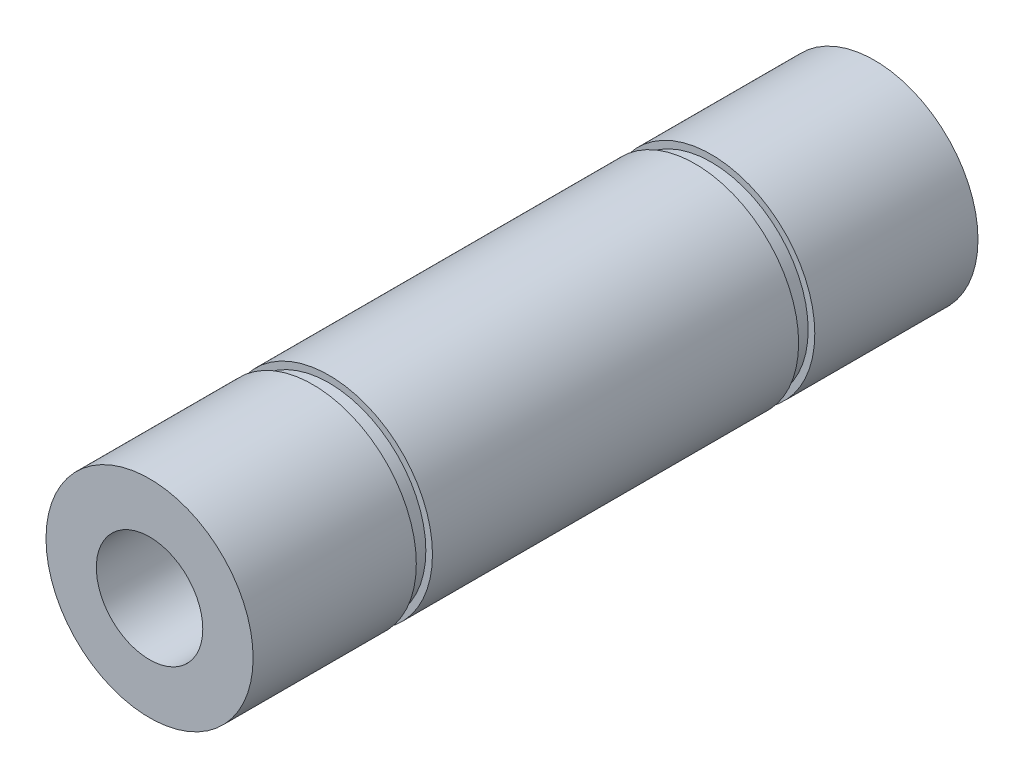
from build123d import *

# Parameters (mm, degrees)
SKETCH1_R                    = 6.35
EXTRUDE1_DEPTH               = 22.225
F_5_16_18_TAPPED_HOLE1_D     = 6.5278
F_5_16_18_TAPPED_HOLE1_DEPTH = 20.32
F_5_16_18_TAPPED_HOLE1_TIP   = 1.961148974
F_5_16_18_TAPPED_HOLE2_D     = 6.5278
F_5_16_18_TAPPED_HOLE2_DEPTH = 20.32
F_5_16_18_TAPPED_HOLE2_TIP   = 1.961148974
SKETCH6_W                    = 0.9906
SKETCH6_H                    = 0.4064


with BuildPart() as part:
    # Sketch1 → Extrude1 (new body, symmetric)
    with BuildSketch(Plane.XY):
        Circle(SKETCH1_R)
    extrude(amount=EXTRUDE1_DEPTH, both=True)

    # 5/16-18 Tapped Hole1
    with Locations(Plane.XY.offset(22.225)):
        with Locations((0, 0)):
            Hole(F_5_16_18_TAPPED_HOLE1_D / 2, depth=F_5_16_18_TAPPED_HOLE1_DEPTH)
            with Locations((0, 0, -(F_5_16_18_TAPPED_HOLE1_DEPTH + F_5_16_18_TAPPED_HOLE1_TIP / 2))):  # 118° drill point
                Cone(0, F_5_16_18_TAPPED_HOLE1_D / 2, F_5_16_18_TAPPED_HOLE1_TIP, mode=Mode.SUBTRACT)

    # 5/16-18 Tapped Hole2
    with Locations(Plane(origin=(0, 0, -22.225), x_dir=(-1, 0, 0), z_dir=(0, 0, -1))):
        with Locations((0, 0)):
            Hole(F_5_16_18_TAPPED_HOLE2_D / 2, depth=F_5_16_18_TAPPED_HOLE2_DEPTH)
            with Locations((0, 0, -(F_5_16_18_TAPPED_HOLE2_DEPTH + F_5_16_18_TAPPED_HOLE2_TIP / 2))):  # 118° drill point
                Cone(0, F_5_16_18_TAPPED_HOLE2_D / 2, F_5_16_18_TAPPED_HOLE2_TIP, mode=Mode.SUBTRACT)

    # Sketch6 → Cut-Revolve1 (revolve, cut)
    with BuildSketch(Plane(origin=(0, 0, 0), x_dir=(0, 0, -1), z_dir=(1, 0, 0))):
        with Locations((11.7221, 6.1468)):
            Rectangle(SKETCH6_W, SKETCH6_H)
    cut_revolve1 = revolve(axis=Axis((0, 0, 22.225), (0, 0, -1)), mode=Mode.SUBTRACT)

    # Mirror1: Cut-Revolve1 across plane
    add(cut_revolve1.mirror(Plane.XY), mode=Mode.SUBTRACT)


solid = part.part
